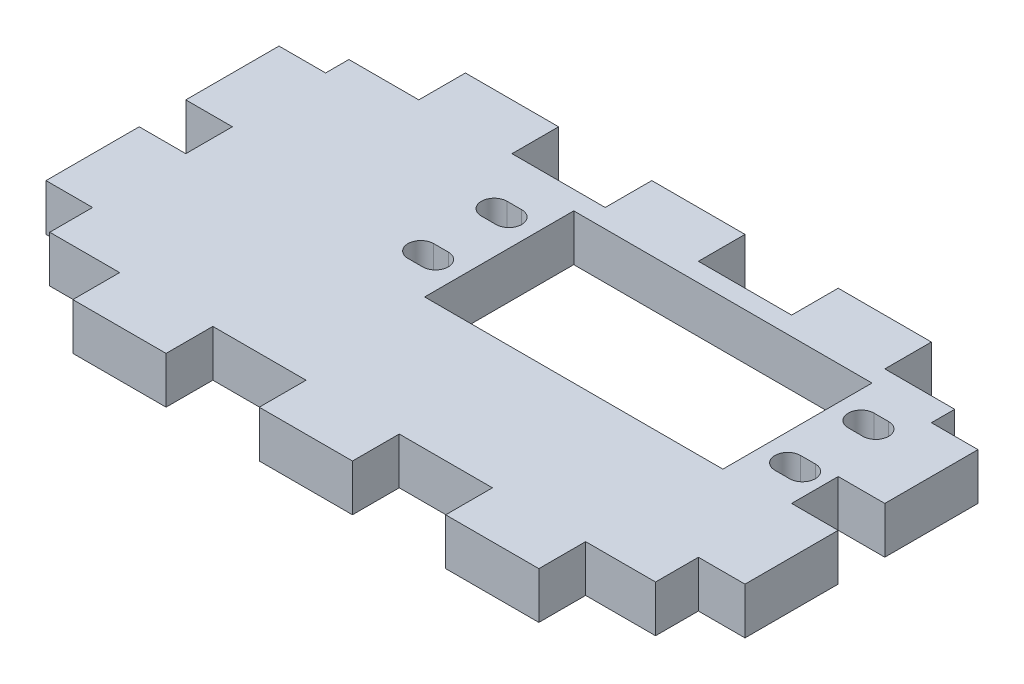
from build123d import *

# Parameters (mm, degrees)
SKETCH2_W           = 53.489335428
SKETCH2_H           = 6.35
BOSS_EXTRUDE1_DEPTH = 95.25
SKETCH3_W           = 6.35
SKETCH3_H           = 6.35
CUT_EXTRUDE1_DEPTH  = 7.35
LPATTERN1_COUNT     = 3
LPATTERN1_PITCH     = 19.05
SKETCH5_W           = 15.875
SKETCH5_H           = 6.374255969
SKETCH5_W_2         = 12.7
SKETCH5_H_2         = 6.35
CUT_EXTRUDE2_DEPTH  = 7.35
SKETCH7_W           = 40.64
SKETCH7_H           = 20.32
CUT_EXTRUDE4_DEPTH  = 7.35


with BuildPart() as part:
    # Sketch2 → Boss-Extrude1 (new body)
    with BuildSketch(Plane(origin=(0, 0, 0), x_dir=(0, 0, -1), z_dir=(1, 0, 0))):
        with Locations((30.077985794, 34.925)):
            Rectangle(SKETCH2_W, SKETCH2_H)
    extrude(amount=BOSS_EXTRUDE1_DEPTH)

    # Sketch3 → Cut-Extrude1 (cut, through all)
    with BuildSketch(Plane(origin=(0, 38.1, 0), x_dir=(1, 0, 0), z_dir=(0, 1, 0))):
        with Locations((3.175, 50.472653508)):
            Rectangle(SKETCH3_W, SKETCH3_H)
        with Locations((92.075, 50.472653508)):
            Rectangle(SKETCH3_W, SKETCH3_H)
    cut_extrude1 = extrude(amount=-CUT_EXTRUDE1_DEPTH, mode=Mode.SUBTRACT)

    # LPattern1: Cut-Extrude1 ×3
    with Locations(*[(0, 0, i * LPATTERN1_PITCH) for i in range(1, LPATTERN1_COUNT)]):
        add(cut_extrude1, mode=Mode.SUBTRACT)

    # Sketch5 → Cut-Extrude2 (cut, through all)
    with BuildSketch(Plane(origin=(0, 38.1, 0), x_dir=(1, 0, 0), z_dir=(0, 1, 0))):
        with Locations((7.9375, 6.520446064)):
            Rectangle(SKETCH5_W, SKETCH5_H)
        with Locations((34.925, 6.520446064)):
            Rectangle(SKETCH5_W_2, SKETCH5_H)
        with Locations((60.325, 6.520446064)):
            Rectangle(SKETCH5_W_2, SKETCH5_H)
        with Locations((87.3125, 6.520446064)):
            Rectangle(SKETCH5_W, SKETCH5_H)
        with Locations((7.9375, 53.647653508)):
            Rectangle(SKETCH5_W, SKETCH5_H_2)
        with Locations((34.925, 53.647653508)):
            Rectangle(SKETCH5_W_2, SKETCH5_H_2)
        with Locations((60.325, 53.647653508)):
            Rectangle(SKETCH5_W_2, SKETCH5_H_2)
        with Locations((87.3125, 53.647653508)):
            Rectangle(SKETCH5_W, SKETCH5_H_2)
    extrude(amount=-CUT_EXTRUDE2_DEPTH, mode=Mode.SUBTRACT)

    # Sketch7 → Cut-Extrude4 (cut, through all)
    with BuildSketch(Plane(origin=(0, 38.1, 0), x_dir=(1, 0, 0), z_dir=(0, 1, 0))):
        with Locations((59.85, 37.772653508)):
            Rectangle(SKETCH7_W, SKETCH7_H)
        with BuildLine():
            Line((83.85, 44.522653508), (85.85, 44.522653508))
            ThreePointArc((85.85, 44.522653508), (87.6, 42.772653508), (85.85, 41.022653508))
            Line((85.85, 41.022653508), (83.85, 41.022653508))
            ThreePointArc((83.85, 41.022653508), (82.1, 42.772653508), (83.85, 44.522653508))
        make_face()
        with BuildLine():
            Line((83.85, 34.522653508), (85.85, 34.522653508))
            ThreePointArc((85.85, 34.522653508), (87.6, 32.772653508), (85.85, 31.022653508))
            Line((85.85, 31.022653508), (83.85, 31.022653508))
            ThreePointArc((83.85, 31.022653508), (82.1, 32.772653508), (83.85, 34.522653508))
        make_face()
        with BuildLine():
            Line((35.85, 41.022653508), (33.85, 41.022653508))
            ThreePointArc((33.85, 41.022653508), (32.1, 42.772653508), (33.85, 44.522653508))
            Line((33.85, 44.522653508), (35.85, 44.522653508))
            ThreePointArc((35.85, 44.522653508), (37.6, 42.772653508), (35.85, 41.022653508))
        make_face()
        with BuildLine():
            Line((35.85, 31.022653508), (33.85, 31.022653508))
            ThreePointArc((33.85, 31.022653508), (32.1, 32.772653508), (33.85, 34.522653508))
            Line((33.85, 34.522653508), (35.85, 34.522653508))
            ThreePointArc((35.85, 34.522653508), (37.6, 32.772653508), (35.85, 31.022653508))
        make_face()
    extrude(amount=-CUT_EXTRUDE4_DEPTH, mode=Mode.SUBTRACT)


solid = part.part
